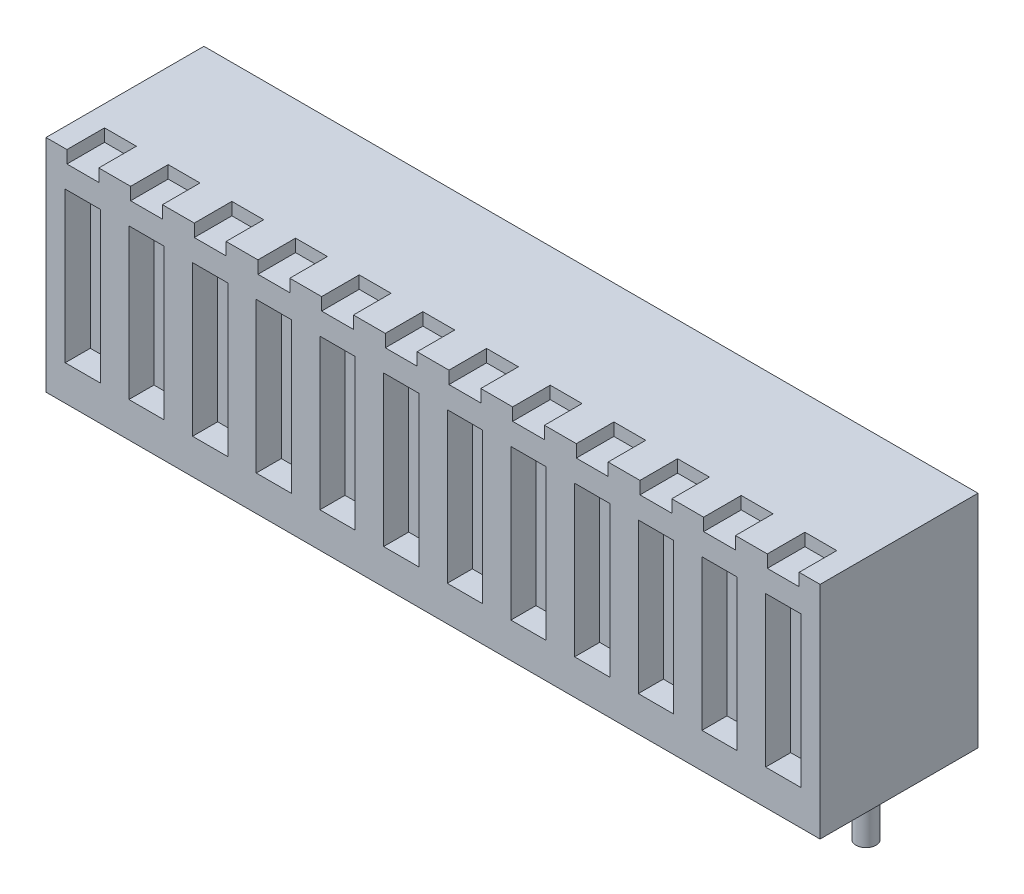
from build123d import *

# Parameters (mm, degrees)
SKETCH2_W           = 30.88
SKETCH2_H           = 6.3
BOSS_EXTRUDE1_DEPTH = 8.8
SKETCH3_R           = 0.4
BOSS_EXTRUDE2_DEPTH = 2.4
SKETCH4_W           = 1.405361948
SKETCH4_H           = 6
CUT_EXTRUDE1_DEPTH  = 1
SKETCH5_W           = 1.27
SKETCH5_H           = 1.5
CUT_EXTRUDE2_DEPTH  = 0.5
LPATTERN1_COUNT     = 12
LPATTERN1_PITCH     = 2.54


with BuildPart() as part:
    # Sketch2 → Boss-Extrude1 (new body)
    with BuildSketch(Plane(origin=(0, 0, 0), x_dir=(1, 0, 0), z_dir=(0, 1, 0))):
        Rectangle(SKETCH2_W, SKETCH2_H)
    extrude(amount=BOSS_EXTRUDE1_DEPTH)

    # Sketch3 → Boss-Extrude2 (add)
    with BuildSketch(Plane.XZ):
        with Locations((-13.97, -0.15)):
            Circle(SKETCH3_R)
    boss_extrude2 = extrude(amount=BOSS_EXTRUDE2_DEPTH)

    # Sketch4 → Cut-Extrude1 (cut)
    with BuildSketch(Plane.XY.offset(3.15)):
        with Locations((-13.97, 4.4)):
            Rectangle(SKETCH4_W, SKETCH4_H)
    cut_extrude1 = extrude(amount=-CUT_EXTRUDE1_DEPTH, mode=Mode.SUBTRACT)

    # Sketch5 → Cut-Extrude2 (cut)
    with BuildSketch(Plane(origin=(0, 8.8, 0), x_dir=(1, 0, 0), z_dir=(0, 1, 0))):
        with Locations((-13.97, -2.4)):
            Rectangle(SKETCH5_W, SKETCH5_H)
    cut_extrude2 = extrude(amount=-CUT_EXTRUDE2_DEPTH, mode=Mode.SUBTRACT)

    # LPattern1: Boss-Extrude2, Cut-Extrude1, Cut-Extrude2 ×12
    with Locations(*[(i * LPATTERN1_PITCH, 0, 0) for i in range(1, LPATTERN1_COUNT)]):
        add(boss_extrude2)
        add(cut_extrude1, mode=Mode.SUBTRACT)
        add(cut_extrude2, mode=Mode.SUBTRACT)


solid = part.part
